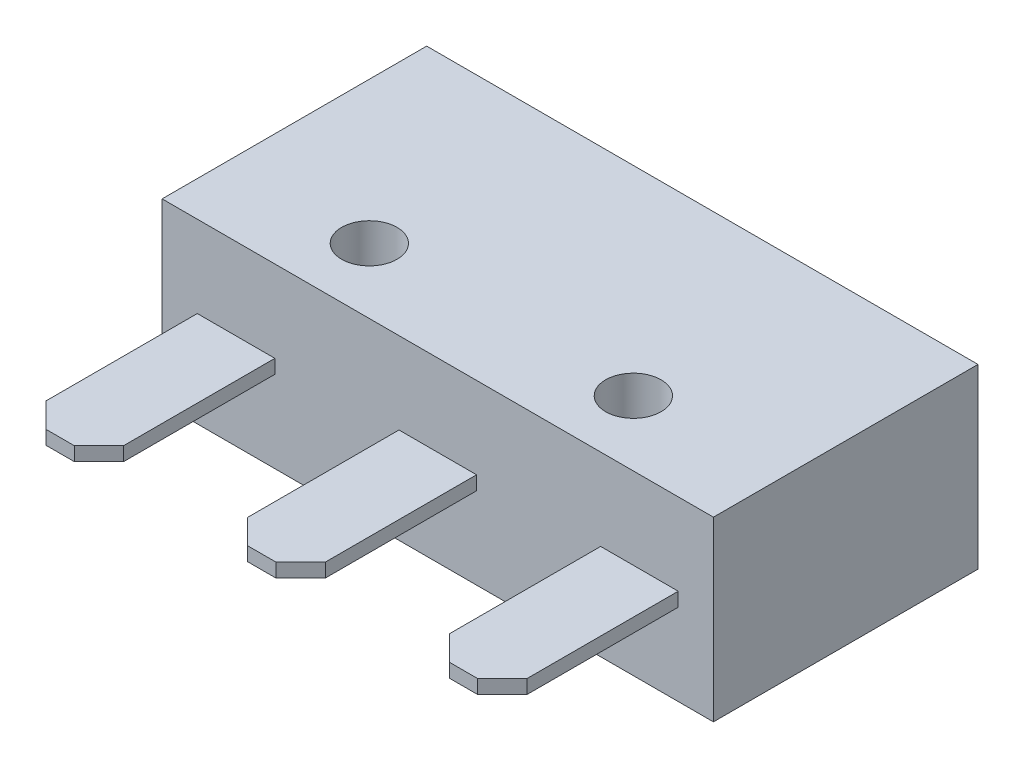
from build123d import *

# Parameters (mm, degrees)
SKETCH1_W           = 19.9
SKETCH1_H           = 9.55
SKETCH1_R           = 1
BOSS_EXTRUDE1_DEPTH = 6.4
SKETCH2_R           = 1.575054
BOSS_EXTRUDE2_DEPTH = 0.8636
SKETCH3_R           = 1.575054
SKETCH3_R_2         = 0.79375
CUT_EXTRUDE1_DEPTH  = 0.381
SKETCH4_W           = 2.8
SKETCH4_H           = 0.5
BOSS_EXTRUDE3_DEPTH = 6.35
CHAMFER1_SIZE       = 0.889


with BuildPart() as part:
    # Sketch1 → Boss-Extrude1 (new body)
    with BuildSketch(Plane(origin=(0, 0, 0), x_dir=(1, 0, 0), z_dir=(0, 1, 0))):
        with Locations((9.95, 4.775)):
            Rectangle(SKETCH1_W, SKETCH1_H)
        with Locations((5.13, 2.35)):
            Circle(SKETCH1_R, mode=Mode.SUBTRACT)
        with Locations((14.66, 2.35)):
            Circle(SKETCH1_R, mode=Mode.SUBTRACT)
    extrude(amount=BOSS_EXTRUDE1_DEPTH)

    # Sketch2 → Boss-Extrude2 (add)
    with BuildSketch(Plane(origin=(0, 0, -9.55), x_dir=(-1, 0, 0), z_dir=(0, 0, -1))):
        with Locations((-7.1, 3.2)):
            Circle(SKETCH2_R)
    extrude(amount=BOSS_EXTRUDE2_DEPTH)

    # Sketch3 → Cut-Extrude1 (cut)
    with BuildSketch(Plane(origin=(0, 0, -10.4136), x_dir=(-1, 0, 0), z_dir=(0, 0, -1))):
        with Locations((-7.1, 3.2)):
            Circle(SKETCH3_R)
        with Locations((-7.1, 3.2)):
            Circle(SKETCH3_R_2, mode=Mode.SUBTRACT)
    extrude(amount=-CUT_EXTRUDE1_DEPTH, mode=Mode.SUBTRACT)

    # Sketch4 → Boss-Extrude3 (add)
    with BuildSketch(Plane.XY):
        with Locations((2.67, 3.2)):
            Rectangle(SKETCH4_W, SKETCH4_H)
        with Locations((9.95, 3.2)):
            Rectangle(SKETCH4_W, SKETCH4_H)
        with Locations((17.23, 3.2)):
            Rectangle(SKETCH4_W, SKETCH4_H)
    extrude(amount=BOSS_EXTRUDE3_DEPTH)

    # Chamfer1
    chamfer1_edges = [part.edges().sort_by_distance(p)[0] for p in [
        (1.27, 3.2, 6.35),
        (4.07, 3.2, 6.35),
        (8.55, 3.2, 6.35),
        (11.35, 3.2, 6.35),
        (15.83, 3.2, 6.35),
        (18.63, 3.2, 6.35),
    ]]
    chamfer(chamfer1_edges, length=CHAMFER1_SIZE)


solid = part.part
